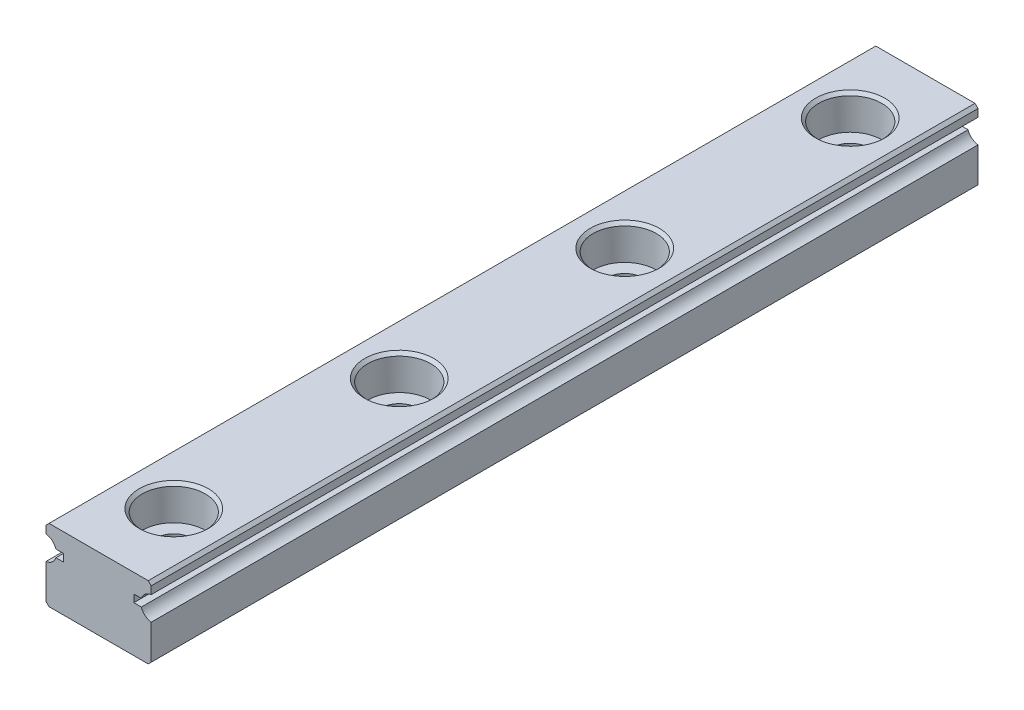
from build123d import *

# Parameters (mm, degrees)
EXTRUDE1_DEPTH             = 55
EXTRUDE2_REACH             = 57.32
SKETCH2_R                  = 1.2
SKETCH_R                   = 2.1
SKETCH_R_2                 = 1.2
EXTRUDE4_DEPTH             = 2.3
CHAMFER1_SIZE              = 0.2
LPATTERN1_COUNT            = 4
LPATTERN1_PITCH            = 15
CHAMFER1_OF_LPATTERN1_SIZE = 0.2


with BuildPart() as part:
    # Sketch1 → Extrude1 (new body)
    with BuildSketch(Plane.XY):
        with BuildLine():
            Line((-3.3, -2.4), (3.3, -2.4))
            Line((3.3, -2.4), (3.5, -2.2))
            Line((3.5, -2.2), (3.5, 0.106274607))
            ThreePointArc((3.5, 0.106274607), (3.091294745, 0.282570681), (2.840065792, 0.65))
            Line((2.840065792, 0.65), (2.340065792, 0.65))
            Line((2.340065792, 0.65), (2.340065792, 1.15))
            Line((2.340065792, 1.15), (2.840065792, 1.15))
            ThreePointArc((2.840065792, 1.15), (3.091294745, 1.517429319), (3.5, 1.693725393))
            Line((3.5, 1.693725393), (3.5, 2.2))
            Line((3.5, 2.2), (3.3, 2.4))
            Line((3.3, 2.4), (-3.3, 2.4))
            Line((-3.3, 2.4), (-3.5, 2.2))
            Line((-3.5, 2.2), (-3.5, 1.693725393))
            ThreePointArc((-3.5, 1.693725393), (-3.091294745, 1.517429319), (-2.840065792, 1.15))
            Line((-2.840065792, 1.15), (-2.340065792, 1.15))
            Line((-2.340065792, 1.15), (-2.340065792, 0.65))
            Line((-2.340065792, 0.65), (-2.840065792, 0.65))
            ThreePointArc((-2.840065792, 0.65), (-3.091294745, 0.282570681), (-3.5, 0.106274607))
            Line((-3.5, 0.106274607), (-3.5, -2.2))
            Line((-3.5, -2.2), (-3.3, -2.4))
        make_face()
    extrude(amount=EXTRUDE1_DEPTH)

    # Sketch2 → Extrude2 (cut, up to next)
    with BuildSketch(Plane(origin=(0, 2.4, 0), x_dir=(1, 0, 0), z_dir=(0, 1, 0)), mode=Mode.PRIVATE) as extrude2_sk1:
        with Locations((0, -5)):
            Circle(SKETCH2_R)
    extrude2_tool1 = extrude(extrude2_sk1.sketch, amount=-EXTRUDE2_REACH, mode=Mode.PRIVATE) & part.part
    extrude2 = extrude2_tool1.solids().sort_by_distance((0, 2.4, 5))[0]
    add(extrude2, mode=Mode.SUBTRACT)

    # Sketch → Extrude4 (cut)
    with BuildSketch(Plane(origin=(0, 2.4, 0), x_dir=(1, 0, 0), z_dir=(0, 1, 0))):
        with Locations((0, -5)):
            Circle(SKETCH_R)
        with Locations((0, -5)):
            Circle(SKETCH_R_2, mode=Mode.SUBTRACT)
    extrude4 = extrude(amount=-EXTRUDE4_DEPTH, mode=Mode.SUBTRACT)

    # Chamfer1
    chamfer1_edges = [part.edges().sort_by_distance(p)[0] for p in [
        (-1.2, -2.4, 5),
        (-2.1, 2.4, 5),
    ]]
    chamfer(chamfer1_edges, length=CHAMFER1_SIZE)

    # LPattern1: Extrude2, Extrude4 ×4
    with Locations(*[(0, 0, i * LPATTERN1_PITCH) for i in range(1, LPATTERN1_COUNT)]):
        add(extrude2, mode=Mode.SUBTRACT)
        add(extrude4, mode=Mode.SUBTRACT)

    # Chamfer1 of LPattern1
    chamfer1_of_lpattern1_edges = [part.edges().sort_by_distance(p)[0] for p in [
        (-1.2, -2.4, 20),
        (-2.1, 2.4, 20),
        (-1.2, -2.4, 35),
        (-2.1, 2.4, 35),
        (-1.2, -2.4, 50),
        (-2.1, 2.4, 50),
    ]]
    chamfer(chamfer1_of_lpattern1_edges, length=CHAMFER1_OF_LPATTERN1_SIZE)


solid = part.part
